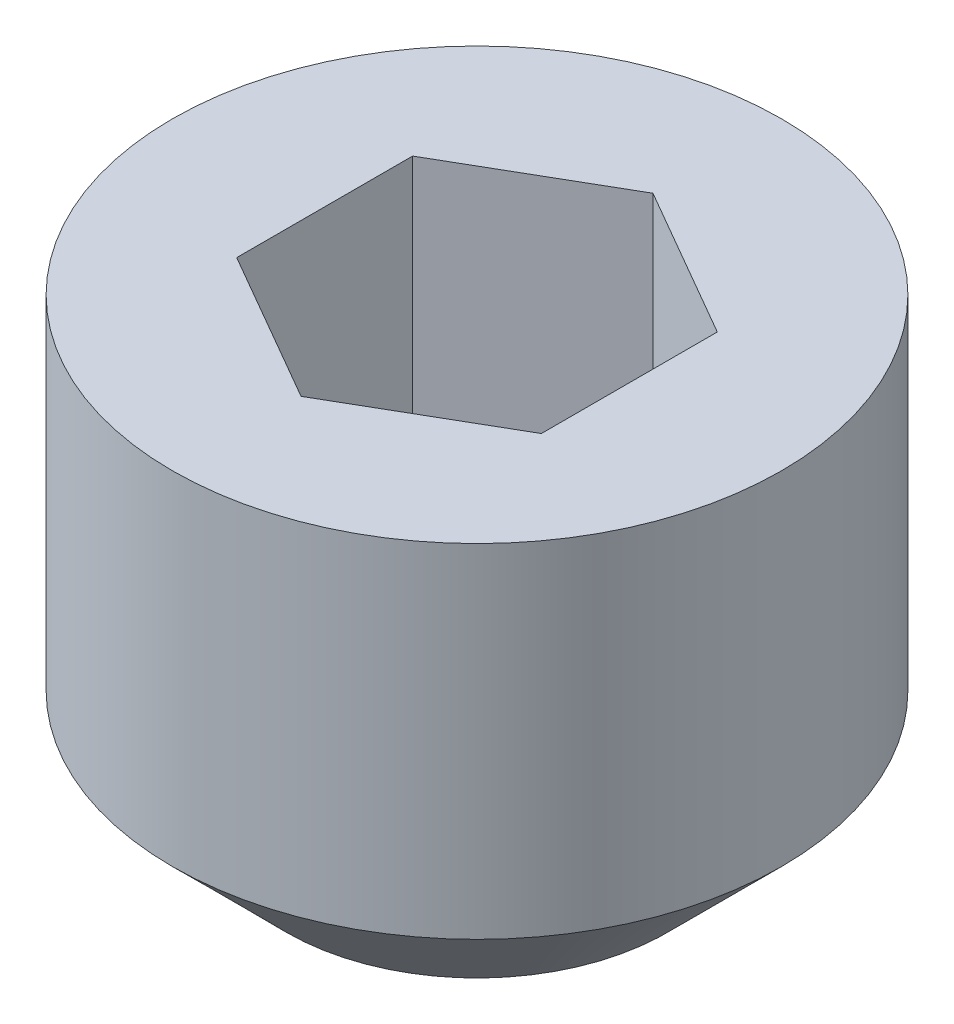
from build123d import *

# Parameters (mm, degrees)
SKETCH1_W          = 2
SKETCH1_H          = 3
CUT_EXTRUDE1_DEPTH = 1.5


with BuildPart() as part:
    # Sketch1 → Revolve1 (revolve)
    with BuildSketch(Plane.XY):
        with Locations((1, 1.5)):
            Rectangle(SKETCH1_W, SKETCH1_H)
    revolve(axis=Axis((0, 3, 0), (0, -1, 0)))

    # Sketch2 → Cut-Revolve1 (revolve, cut)
    with BuildSketch(Plane.XY):
        Polygon((0, 3), (1, 3), (1, 1.5), (0, 0.922649731), align=None)
    revolve(axis=Axis((0, 3, 0), (0, -1, 0)), mode=Mode.SUBTRACT)

    # Sketch3 → Cut-Extrude1 (cut)
    with BuildSketch(Plane(origin=(0, 3, 0), x_dir=(1, 0, 0), z_dir=(0, 1, 0))):
        Polygon((0, 1.154700538), (-1, 0.577350269), (-1, -0.577350269), (0, -1.154700538), (1, -0.577350269), (1, 0.577350269), align=None)
    extrude(amount=-CUT_EXTRUDE1_DEPTH, mode=Mode.SUBTRACT)

    # Sketch4 → Cut-Revolve2 (revolve, cut)
    with BuildSketch(Plane.XY):
        Polygon((1.25, 0), (2, 0), (2, 0.75), align=None)
    revolve(axis=Axis((0, 0, 0), (0, 1, 0)), mode=Mode.SUBTRACT)


solid = part.part
